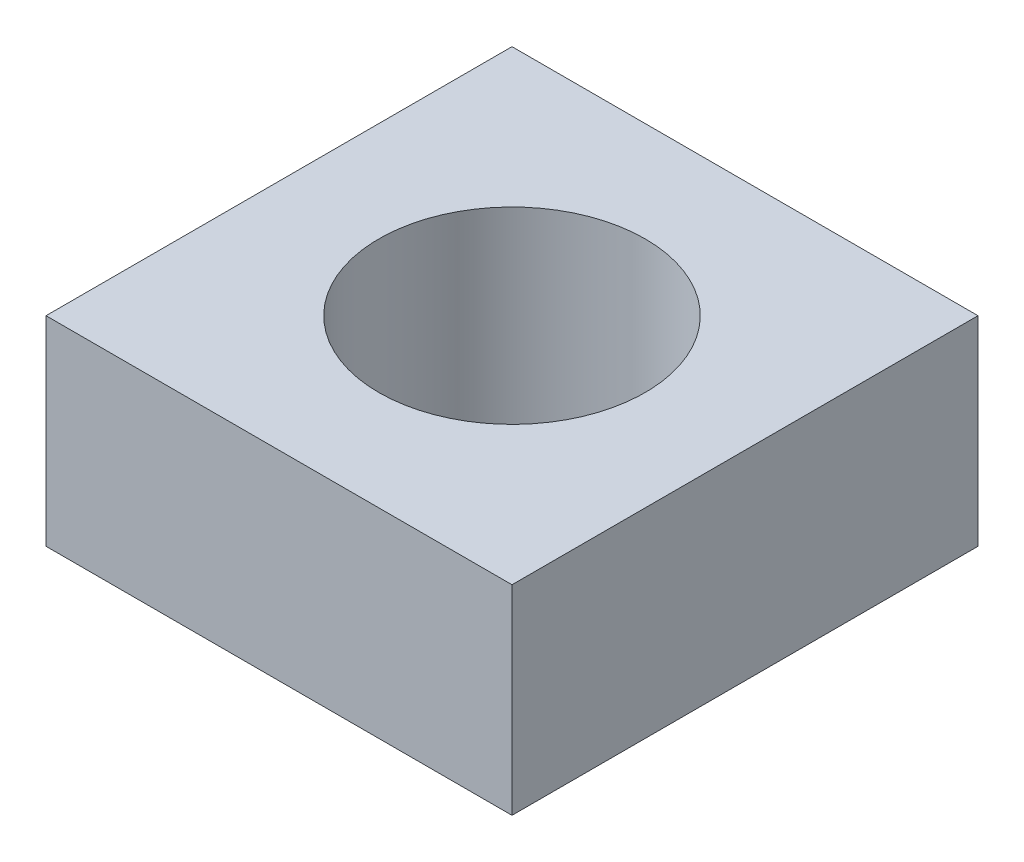
from build123d import *

# Parameters (mm, degrees)
SKETCH1_W           = 22.225
SKETCH1_H           = 9.525
BOSS_EXTRUDE1_DEPTH = 22.225
SKETCH2_R           = 6.35
CUT_EXTRUDE1_DEPTH  = 22.225


with BuildPart() as part:
    # Sketch1 → Boss-Extrude1 (new body)
    with BuildSketch(Plane.XY):
        with Locations((11.1125, 4.7625)):
            Rectangle(SKETCH1_W, SKETCH1_H)
    extrude(amount=BOSS_EXTRUDE1_DEPTH)

    # Sketch2 → Cut-Extrude1 (cut)
    with BuildSketch(Plane(origin=(0, 9.525, 0), x_dir=(1, 0, 0), z_dir=(0, 1, 0))):
        with Locations((11.1125, -11.1125)):
            Circle(SKETCH2_R)
    extrude(amount=-CUT_EXTRUDE1_DEPTH, mode=Mode.SUBTRACT)


solid = part.part
